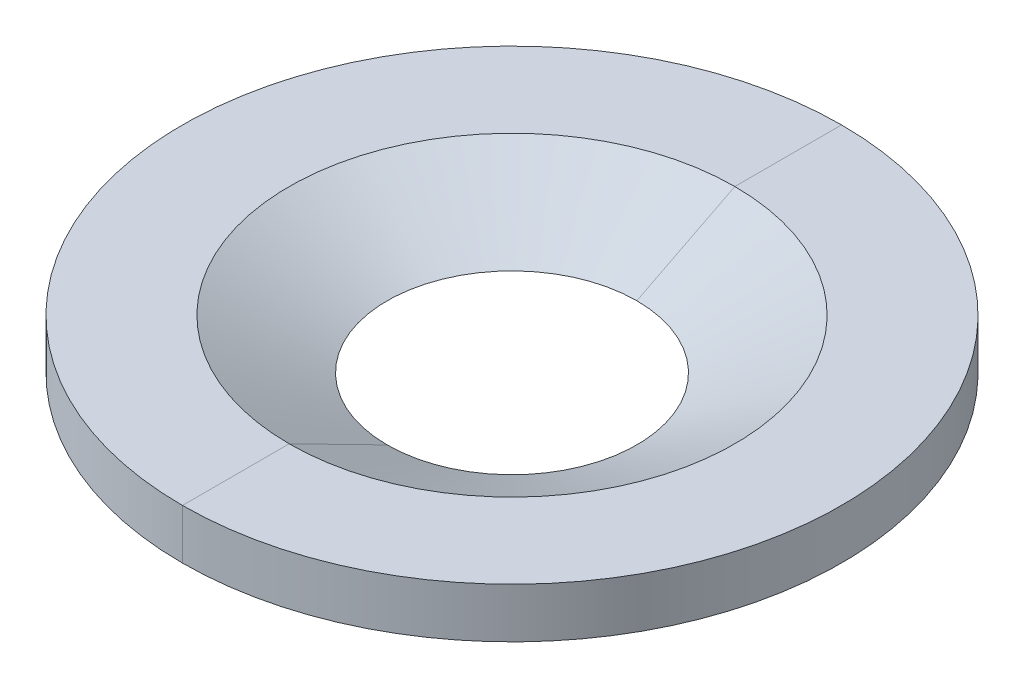
from build123d import *

# Parameters (mm, degrees)
SKETCH1_R           = 83.82
SKETCH1_R_2         = 31.75
BOSS_EXTRUDE1_DEPTH = 6.35


with BuildPart() as part:
    # Sketch1 → Boss-Extrude1 (new body, symmetric)
    with BuildSketch(Plane(origin=(0, 0, 0), x_dir=(1, 0, 0), z_dir=(0, 1, 0))):
        Circle(SKETCH1_R)
        Circle(SKETCH1_R_2, mode=Mode.SUBTRACT)
    extrude(amount=BOSS_EXTRUDE1_DEPTH, both=True)

    # Sketch3 → Cut-Revolve1 (revolve, cut)
    with BuildSketch(Plane.XY):
        Polygon((-31.75, -6.35), (-56.67515342, 6.35), (-31.75, 6.35), align=None)
    revolve(axis=Axis((0, 23.278593151, 0), (0, -1, 0)), mode=Mode.SUBTRACT)


with BuildPart() as body_2:
    # Split1: the piece on the far side of the plane
    add(part.part)
    split(bisect_by=Plane(origin=(0, 0, 0), x_dir=(0, 0, 1), z_dir=(1, 0, 0)), keep=Keep.BOTTOM)


with BuildPart() as part_1:
    add(part.part)

    # Split1
    split(bisect_by=Plane(origin=(0, 0, 0), x_dir=(0, 0, 1), z_dir=(1, 0, 0)), keep=Keep.TOP)


solid = Compound([body_2.part, part_1.part])
